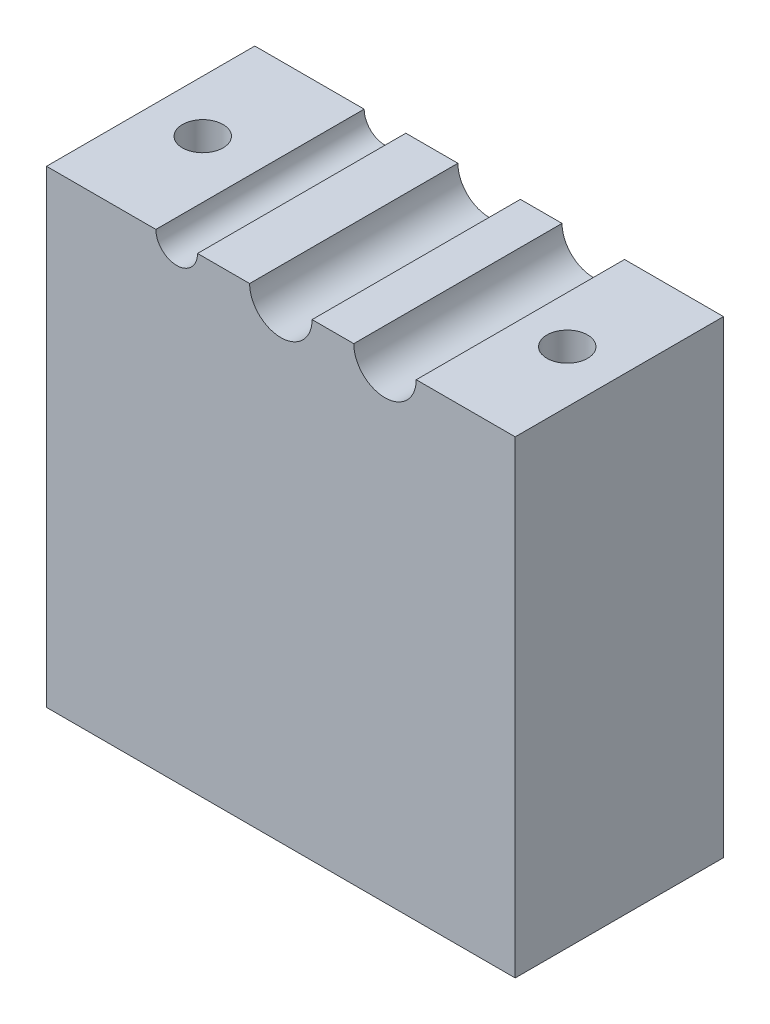
from build123d import *

# Parameters (mm, degrees)
BOSS_EXTRUDE1_DEPTH = 20
SKETCH2_R           = 1.95
CUT_EXTRUDE1_DEPTH  = 20


with BuildPart() as part:
    # Sketch1 → Boss-Extrude1 (new body)
    with BuildSketch(Plane.XY):
        with BuildLine():
            Line((-22.5, -22.5), (22.5, -22.5))
            Line((22.5, -22.5), (22.5, 22.5))
            Line((22.5, 22.5), (13, 22.5))
            ThreePointArc((13, 22.5), (10, 19.5), (7, 22.5))
            Line((7, 22.5), (3, 22.5))
            ThreePointArc((3, 22.5), (0, 19.5), (-3, 22.5))
            Line((-3, 22.5), (-8, 22.5))
            ThreePointArc((-8, 22.5), (-10, 20.5), (-12, 22.5))
            Line((-12, 22.5), (-22.5, 22.5))
            Line((-22.5, 22.5), (-22.5, -22.5))
        make_face()
    extrude(amount=BOSS_EXTRUDE1_DEPTH)

    # Sketch2 → Cut-Extrude1 (cut)
    with BuildSketch(Plane(origin=(0, 22.5, 0), x_dir=(1, 0, 0), z_dir=(0, 1, 0))):
        with Locations((-17.5, -10)):
            Circle(SKETCH2_R)
        with Locations((17.5, -10)):
            Circle(SKETCH2_R)
    extrude(amount=-CUT_EXTRUDE1_DEPTH, mode=Mode.SUBTRACT)


solid = part.part
